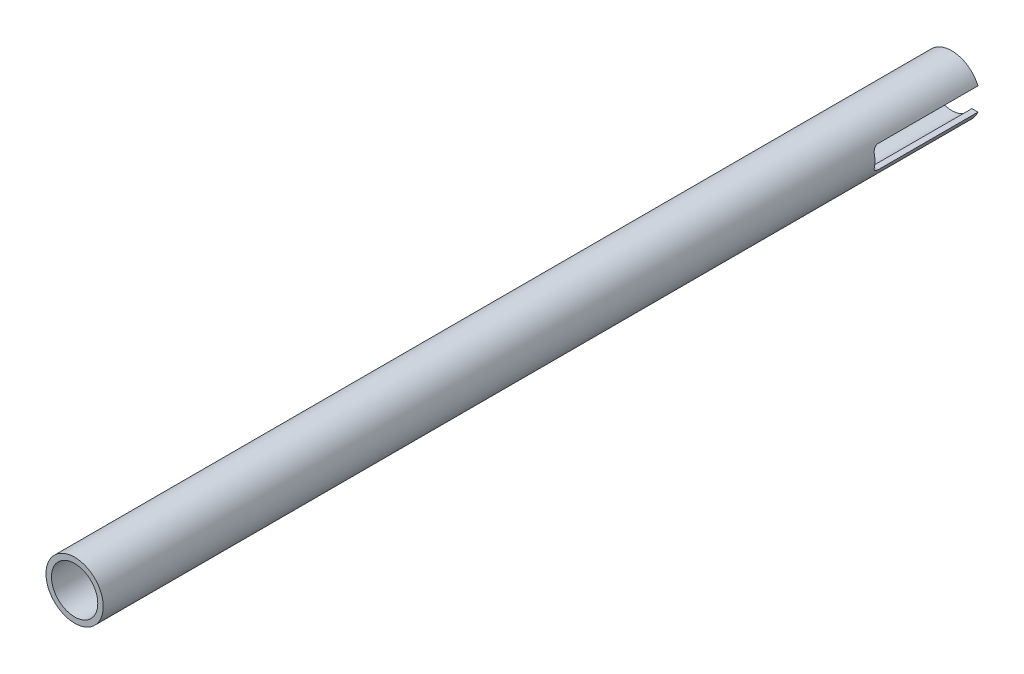
from build123d import *

# Parameters (mm, degrees)
SKETCH1_R               = 8.001
SKETCH1_R_2             = 6.477
BOSS_EXTRUDE1_DEPTH     = 245.11
CUT_EXTRUDE1_DEPTH      = 9.001
CUT_EXTRUDE1_DEPTH_BACK = 9.001


with BuildPart() as part:
    # Sketch1 → Boss-Extrude1 (new body)
    with BuildSketch(Plane.XY):
        Circle(SKETCH1_R)
        Circle(SKETCH1_R_2, mode=Mode.SUBTRACT)
    extrude(amount=BOSS_EXTRUDE1_DEPTH)

    # Sketch2 → Cut-Extrude1 (cut, two sides)
    with BuildSketch(Plane(origin=(0, 0, 0), x_dir=(0, 0, -1), z_dir=(1, 0, 0))) as cut_extrude1_sk:
        with BuildLine():
            Line((500.729314698, 3.175), (0, 3.175))
            Line((0, 3.175), (-27.94, 3.175))
            ThreePointArc((-27.94, 3.175), (-29.017630735, 2.728630735), (-29.464, 1.651))
            Line((-29.464, 1.651), (-29.464, -1.651))
            ThreePointArc((-29.464, -1.651), (-29.017630735, -2.728630735), (-27.94, -3.175))
            Line((-27.94, -3.175), (0, -3.175))
            Line((0, -3.175), (500.729314698, -3.175))
            Line((500.729314698, -3.175), (1502.187944094, -3.175))
            Line((1502.187944094, -3.175), (1502.187944094, 3.175))
            Line((1502.187944094, 3.175), (500.729314698, 3.175))
        make_face()
    extrude(amount=CUT_EXTRUDE1_DEPTH, mode=Mode.SUBTRACT)
    extrude(cut_extrude1_sk.sketch, amount=-CUT_EXTRUDE1_DEPTH_BACK, mode=Mode.SUBTRACT)


solid = part.part
